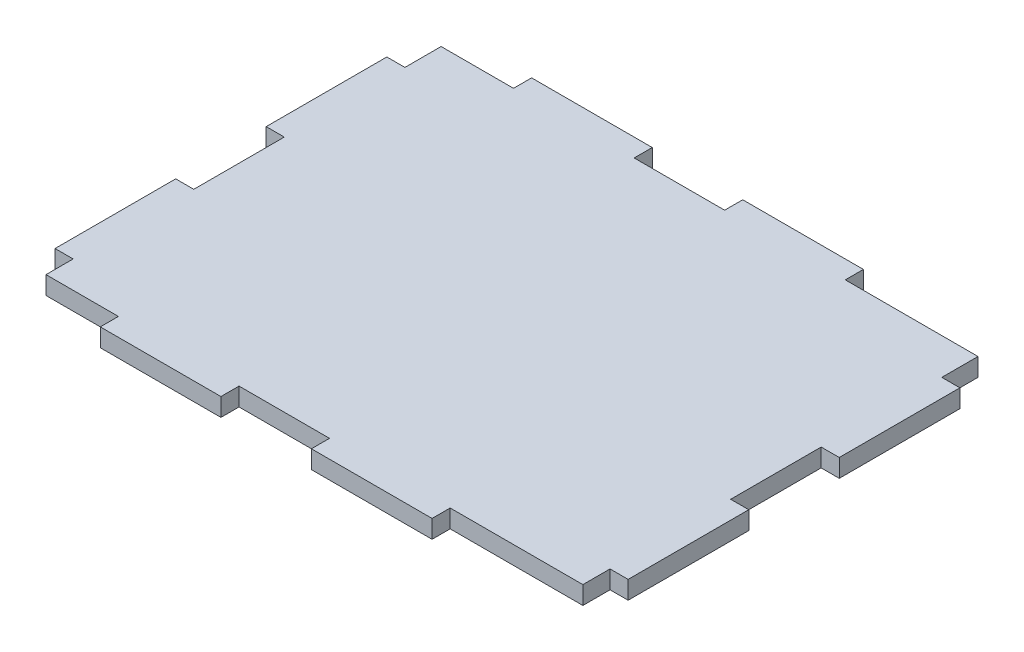
from build123d import *

# Parameters (mm, degrees)
BOSS_EXTRUDE1_DEPTH = 3


with BuildPart() as part:
    # Sketch1 → Boss-Extrude1 (new body)
    with BuildSketch(Plane(origin=(0, 0, 0), x_dir=(1, 0, 0), z_dir=(0, 1, 0))):
        Polygon((12, 65.5), (0, 65.5), (0, 59.5), (-3, 59.5), (-3, 39.5), (0, 39.5), (0, 24.5), (-3, 24.5), (-3, 4.5), (0, 4.5), (0, 0), (12, 0), (12, -3), (32, -3), (32, 0), (47, 0), (47, -3), (67, -3), (67, 0), (89, 0), (89, 4.5), (92, 4.5), (92, 24.5), (89, 24.5), (89, 39.5), (92, 39.5), (92, 59.5), (89, 59.5), (89, 65.5), (67, 65.5), (67, 68.5), (47, 68.5), (47, 65.5), (32, 65.5), (32, 68.5), (12, 68.5), align=None)
    extrude(amount=BOSS_EXTRUDE1_DEPTH)


solid = part.part
